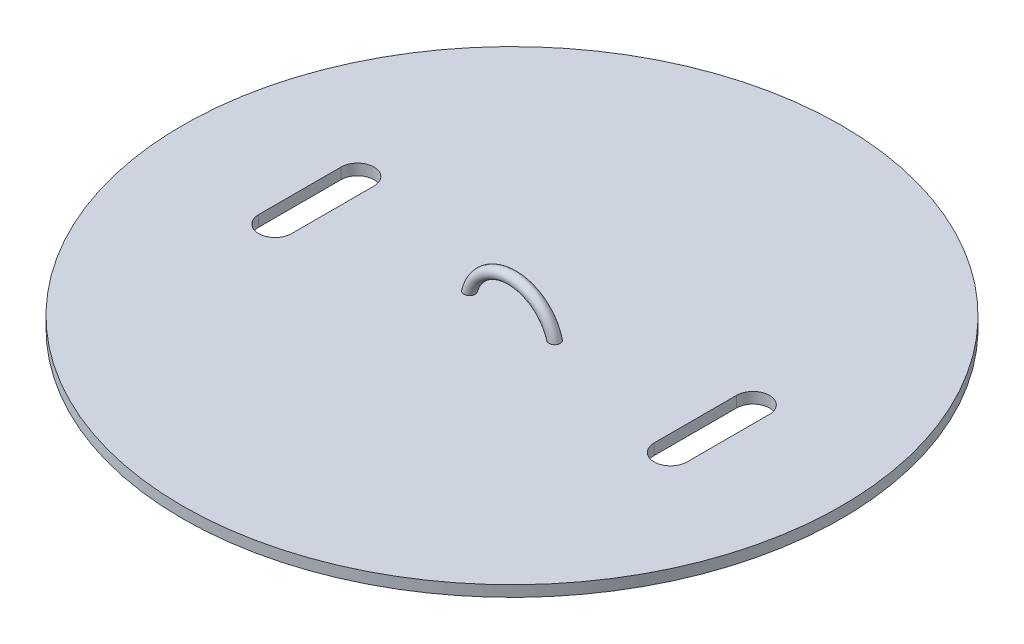
from build123d import *

# Parameters (mm, degrees)
SKETCH1_R           = 60
BOSS_EXTRUDE1_DEPTH = 2
SKETCH3_R           = 1
REVOLVE1_ANGLE      = 180
CUT_EXTRUDE1_DEPTH  = 10


with BuildPart() as part:
    # Sketch1 → Boss-Extrude1 (new body)
    with BuildSketch(Plane(origin=(0, 0, 0), x_dir=(1, 0, 0), z_dir=(0, 1, 0))):
        with Locations((0, -137.725986214)):
            Circle(SKETCH1_R)
    extrude(amount=BOSS_EXTRUDE1_DEPTH)

    # Sketch3 → Revolve1 (revolve)
    with BuildSketch(Plane(origin=(0, 0, 0), x_dir=(1, 0, 0), z_dir=(0, 1, 0))):
        with Locations((8, -137.725986214)):
            Circle(SKETCH3_R)
    revolve(axis=Axis((0, 0, 77.725986214), (0, 0, 1)), revolution_arc=REVOLVE1_ANGLE)

    # Sketch4 → Cut-Extrude1 (cut)
    with BuildSketch(Plane(origin=(0, 2, 0), x_dir=(1, 0, 0), z_dir=(0, 1, 0))):
        with BuildLine():
            Line((39, -129.850097306), (39, -144.850097306))
            ThreePointArc((39, -144.850097306), (36, -147.850097306), (33, -144.850097306))
            Line((33, -144.850097306), (33, -129.850097306))
            ThreePointArc((33, -129.850097306), (36, -126.850097306), (39, -129.850097306))
        make_face()
        with BuildLine():
            Line((-39, -129.850097306), (-39, -144.850097306))
            ThreePointArc((-39, -144.850097306), (-36, -147.850097306), (-33, -144.850097306))
            Line((-33, -144.850097306), (-33, -129.850097306))
            ThreePointArc((-33, -129.850097306), (-36, -126.850097306), (-39, -129.850097306))
        make_face()
    extrude(amount=-CUT_EXTRUDE1_DEPTH, mode=Mode.SUBTRACT)


solid = part.part
